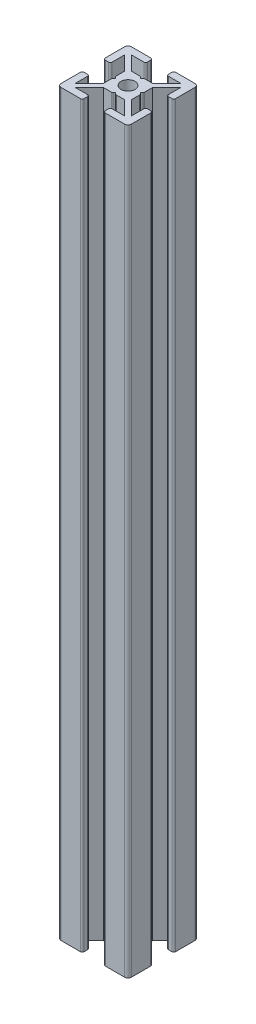
from build123d import *

# Parameters (mm, degrees)
SKETCH1_R           = 2
BOSS_EXTRUDE1_DEPTH = 210
FILLET1_R           = 1
FILLET2_R           = 0.5
FILLET4_R           = 0.5


with BuildPart() as part:
    # Sketch1 → Boss-Extrude1 (new body)
    with BuildSketch(Plane(origin=(0, 0, 0), x_dir=(1, 0, 0), z_dir=(0, 1, 0))):
        Polygon((7, 18), (7, 20), (0, 20), (0, 13), (2, 13), (2, 17), (6, 13), (6, 10.5), (6.5, 10), (6, 9.5), (6, 7), (2, 3), (2, 7), (0, 7), (0, 0), (7, 0), (7, 2), (3, 2), (7, 6), (9.5, 6), (10, 6.5), (10.5, 6), (13, 6), (17, 2), (13, 2), (13, 0), (20, 0), (20, 7), (18, 7), (18, 3), (14, 7), (14, 9.5), (13.5, 10), (14, 10.5), (14, 13), (18, 17), (18, 13), (20, 13), (20, 20), (13, 20), (13, 18), (17, 18), (13, 14), (10.5, 14), (10, 13.5), (9.5, 14), (7, 14), (3, 18), align=None)
        with Locations((10, 10)):
            Circle(SKETCH1_R, mode=Mode.SUBTRACT)
    extrude(amount=BOSS_EXTRUDE1_DEPTH)

    # Fillet1
    fillet1_edges = [part.edges().sort_by_distance(p)[0] for p in [
        (0, 105, -20),
        (20, 105, -20),
        (20, 105, 0),
        (0, 105, 0),
    ]]
    fillet(fillet1_edges, radius=FILLET1_R)

    # Fillet2
    fillet2_edges = [part.edges().sort_by_distance(p)[0] for p in [
        (2, 105, -13),
        (0, 105, -13),
        (7, 105, -20),
        (7, 105, -18),
        (13, 105, -18),
        (13, 105, -20),
        (20, 105, -13),
        (18, 105, -13),
        (18, 105, -7),
        (20, 105, -7),
        (13, 105, 0),
        (13, 105, -2),
        (7, 105, -2),
        (7, 105, 0),
        (0, 105, -7),
        (2, 105, -7),
    ]]
    fillet(fillet2_edges, radius=FILLET2_R)

    # Fillet4
    fillet4_edges = [part.edges().sort_by_distance(p)[0] for p in [
        (9.5, 105, -14),
        (10.5, 105, -14),
        (14, 105, -10.5),
        (14, 105, -9.5),
        (10.5, 105, -6),
        (9.5, 105, -6),
        (6, 105, -9.5),
        (6, 105, -10.5),
    ]]
    fillet(fillet4_edges, radius=FILLET4_R)


solid = part.part
